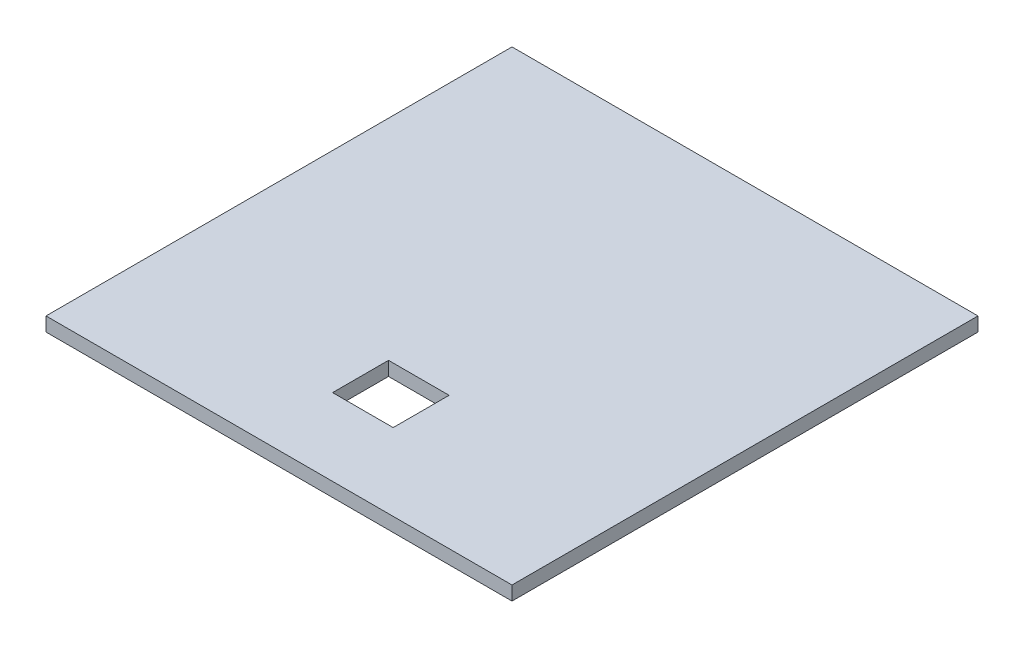
from build123d import *

# Parameters (mm, degrees)
SKETCH1_W           = 100
SKETCH1_H           = 100
BOSS_EXTRUDE1_DEPTH = 3
SKETCH3_W           = 13
SKETCH3_H           = 12
CUT_EXTRUDE3_DEPTH  = 3


with BuildPart() as part:
    # Sketch1 → Boss-Extrude1 (new body)
    with BuildSketch(Plane(origin=(0, 0, 0), x_dir=(1, 0, 0), z_dir=(0, 1, 0))):
        Rectangle(SKETCH1_W, SKETCH1_H)
    extrude(amount=BOSS_EXTRUDE1_DEPTH)

    # Sketch3 → Cut-Extrude3 (cut)
    with BuildSketch(Plane.XZ):
        with Locations((1.5, 27.5)):
            Rectangle(SKETCH3_W, SKETCH3_H)
    extrude(amount=-CUT_EXTRUDE3_DEPTH, mode=Mode.SUBTRACT)


solid = part.part
